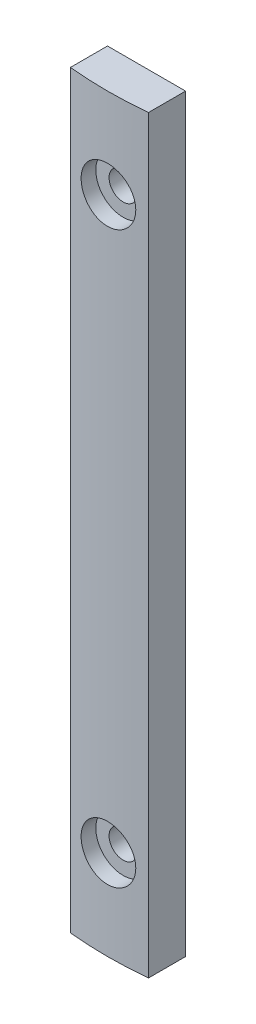
from build123d import *

# Parameters (mm, degrees)
EXTRUDE_1_DEPTH              = 96
HOLE_WIZARD_M3_1_D           = 3.6
HOLE_WIZARD_M3_1_DEPTH       = 5
HOLE_WIZARD_M3_1_CBORE_D     = 7
HOLE_WIZARD_M3_1_CBORE_DEPTH = 2


with BuildPart() as part:
    # 草图1 → 凸台-拉伸1 (new body)
    with BuildSketch(Plane(origin=(0, 96, 0), x_dir=(1, 0, 0), z_dir=(0, 1, 0))):
        with BuildLine():
            Line((1055, -2.499371855), (1055, 2.25))
            Line((1055, 2.25), (1045, 2.25))
            Line((1045, 2.25), (1045, -2.499371855))
            ThreePointArc((1045, -2.499371855), (1050, -2.75), (1055, -2.499371855))
        make_face()
    extrude(amount=-EXTRUDE_1_DEPTH)

    # M3 六角头机械螺钉的柱形沉头孔1
    with Locations(Plane(origin=(1050, 84.5, 2.75), x_dir=(0, 1, 0), z_dir=(0, 0, 1))):
        with Locations((0, 0)):
            hole_wizard_m3_1 = CounterBoreHole(HOLE_WIZARD_M3_1_D / 2, HOLE_WIZARD_M3_1_CBORE_D / 2, HOLE_WIZARD_M3_1_CBORE_DEPTH, depth=HOLE_WIZARD_M3_1_DEPTH)

    # 镜向1: M3 六角头机械螺钉的柱形沉头孔1 across plane
    add(hole_wizard_m3_1.mirror(Plane(origin=(0, 48, 0), x_dir=(0, 0, 1), z_dir=(0, -1, 0))), mode=Mode.SUBTRACT)


solid = part.part
